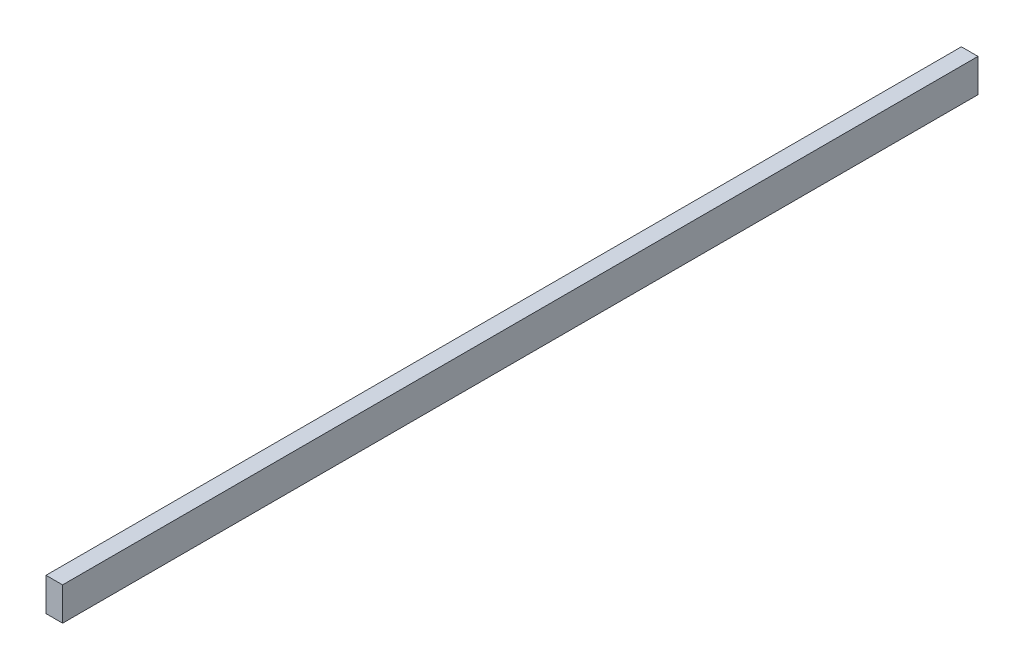
from build123d import *

# Parameters (mm, degrees)
CROQUIS1_W              = 12.7
CROQUIS1_H              = 25.4
SALIENTE_EXTRUIR1_DEPTH = 700


with BuildPart() as part:
    # Croquis1 → Saliente-Extruir1 (new body)
    with BuildSketch(Plane.XY):
        Rectangle(CROQUIS1_W, CROQUIS1_H)
    extrude(amount=-SALIENTE_EXTRUIR1_DEPTH)


solid = part.part
